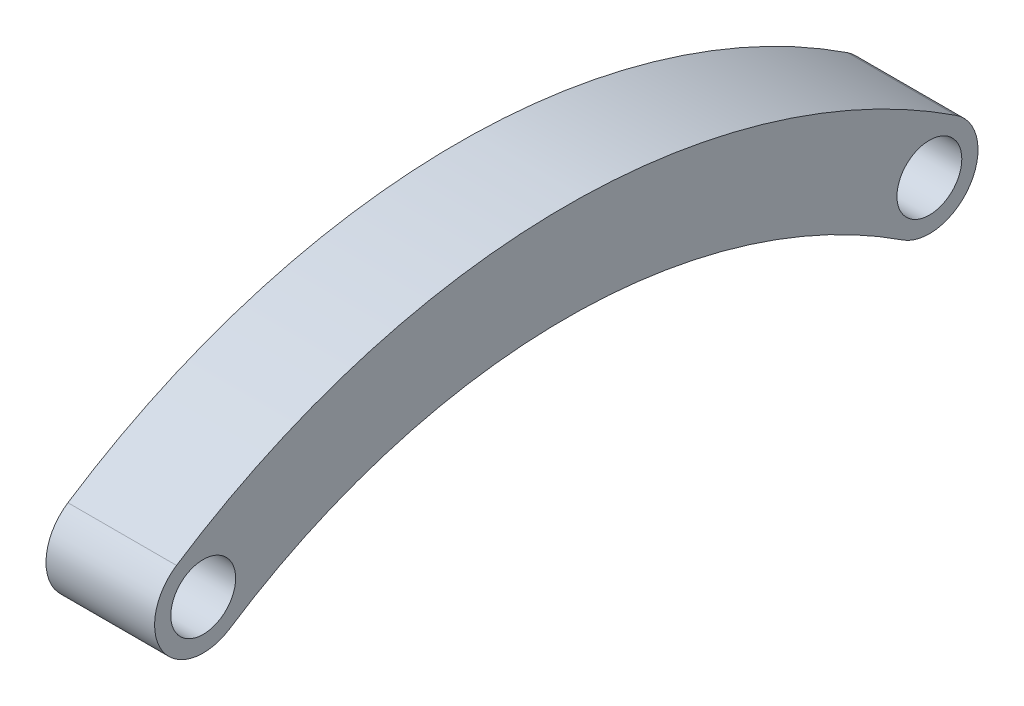
from build123d import *

# Parameters (mm, degrees)
BOSS_EXTRUDE1_DEPTH = 3.35
SKETCH2_R           = 2
CUT_EXTRUDE1_DEPTH  = 6.7


with BuildPart() as part:
    # Sketch1 → Boss-Extrude1 (new body, symmetric)
    with BuildSketch(Plane(origin=(0, 0, 0), x_dir=(0, 0, -1), z_dir=(1, 0, 0))):
        with BuildLine():
            ThreePointArc((0, 0), (10.830584713, -1.585060066), (20.752730266, -6.207289856))
            ThreePointArc((20.752730266, -6.207289856), (24.907289856, -5.347269734), (24.047269734, -1.192710144))
            ThreePointArc((24.047269734, -1.192710144), (12.549962758, 4.163308324), (0, 6))
            ThreePointArc((0, 6), (-12.549962758, 4.163308324), (-24.047269734, -1.192710144))
            ThreePointArc((-24.047269734, -1.192710144), (-24.907289856, -5.347269734), (-20.752730266, -6.207289856))
            ThreePointArc((-20.752730266, -6.207289856), (-10.830584713, -1.585060066), (0, 0))
        make_face()
    extrude(amount=BOSS_EXTRUDE1_DEPTH, both=True)

    # Sketch2 → Cut-Extrude1 (cut)
    with BuildSketch(Plane(origin=(3.35, 0, 0), x_dir=(0, 0, -1), z_dir=(1, 0, 0))):
        with Locations((-22.4, -3.7)):
            Circle(SKETCH2_R)
        with Locations((22.4, -3.7)):
            Circle(SKETCH2_R)
    extrude(amount=-CUT_EXTRUDE1_DEPTH, mode=Mode.SUBTRACT)


solid = part.part
